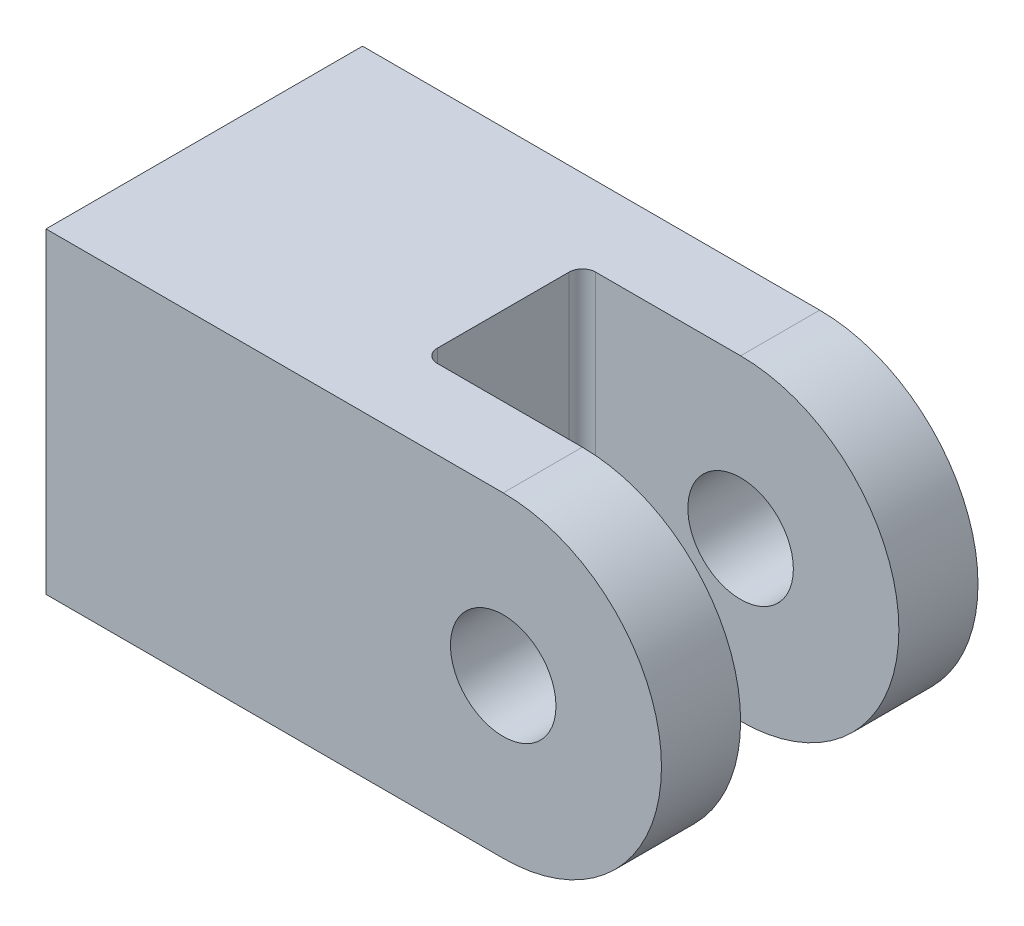
from build123d import *

# Parameters (mm, degrees)
CLEVIS_BODY_EXTRUDE1_DEPTH       = 18
SKETCH2_R                        = 6
PIN_HOLES_CUT_EXTRUDE1_DEPTH     = 18
SKETCH3_R                        = 7.5
THREADED_HOLE_CUT_EXTRUDE2_DEPTH = 25
SKETCH5_W                        = 38
SKETCH5_H                        = 18
CLEVIS_GAP_CUT_EXTRUDE4_DEPTH    = 37
FILLET2_R                        = 1.5
CHAMFER2_SIZE                    = 0.5


with BuildPart() as part:
    # Sketch1 → Clevis Body Extrude1 (new body, symmetric)
    with BuildSketch(Plane.XY):
        with BuildLine():
            Line((0, 0), (52, 0))
            ThreePointArc((52, 0), (70, 18), (52, 36))
            Line((52, 36), (0, 36))
            Line((0, 36), (0, 0))
        make_face()
    extrude(amount=CLEVIS_BODY_EXTRUDE1_DEPTH, both=True)

    # Sketch2 → Pin Holes Cut-Extrude1 (cut, symmetric)
    with BuildSketch(Plane.XY):
        with Locations((52, 18)):
            Circle(SKETCH2_R)
    extrude(amount=PIN_HOLES_CUT_EXTRUDE1_DEPTH, both=True, mode=Mode.SUBTRACT)

    # Sketch3 → Threaded Hole Cut-Extrude2 (cut)
    with BuildSketch(Plane.ZY):
        with Locations((0, 18)):
            Circle(SKETCH3_R)
    extrude(amount=-THREADED_HOLE_CUT_EXTRUDE2_DEPTH, mode=Mode.SUBTRACT)

    # Sketch5 → Clevis Gap Cut-Extrude4 (cut, through all)
    with BuildSketch(Plane(origin=(0, 0, 0), x_dir=(1, 0, 0), z_dir=(0, 1, 0))):
        with Locations((53, 0)):
            Rectangle(SKETCH5_W, SKETCH5_H)
    extrude(amount=CLEVIS_GAP_CUT_EXTRUDE4_DEPTH, mode=Mode.SUBTRACT)

    # Fillet2
    fillet2_edges = [part.edges().sort_by_distance(p)[0] for p in [
        (34, 18, 9),
        (34, 18, -9),
    ]]
    fillet(fillet2_edges, radius=FILLET2_R)

    # Chamfer2
    chamfer2_edges = [part.edges().sort_by_distance(p)[0] for p in [
        (0, 18, -7.5),
    ]]
    chamfer(chamfer2_edges, length=CHAMFER2_SIZE)


solid = part.part
